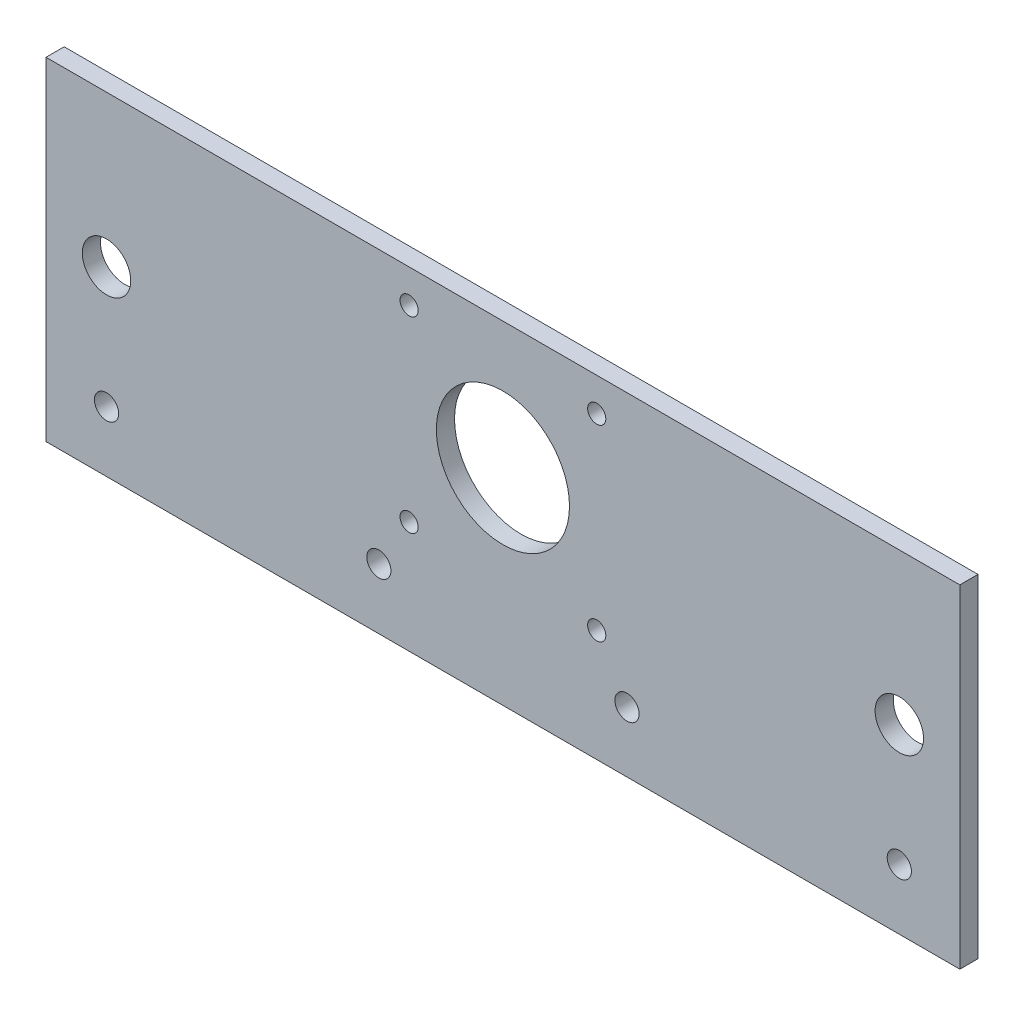
from build123d import *

# Parameters (mm, degrees)
SKIZZE1_W                       = 151
SKIZZE1_H                       = 55
AUFSATZ_LINEAR_AUSTRAGEN1_DEPTH = 3
SKIZZE2_R                       = 11
SCHNITT_LINEAR_AUSTRAGEN1_DEPTH = 17
SKIZZE3_R                       = 1.5
SCHNITT_LINEAR_AUSTRAGEN2_DEPTH = 10
SKIZZE4_R                       = 4
SCHNITT_LINEAR_AUSTRAGEN3_DEPTH = 10
SKIZZE5_R                       = 2
SCHNITT_LINEAR_AUSTRAGEN4_DEPTH = 10


with BuildPart() as part:
    # Skizze1 → Aufsatz-Linear austragen1 (new body)
    with BuildSketch(Plane.XY):
        with Locations((75.5, 27.5)):
            Rectangle(SKIZZE1_W, SKIZZE1_H)
    extrude(amount=AUFSATZ_LINEAR_AUSTRAGEN1_DEPTH)

    # Skizze2 → Schnitt-Linear austragen1 (cut)
    with BuildSketch(Plane.XY.offset(3)):
        with Locations((75.5, 34)):
            Circle(SKIZZE2_R)
    extrude(amount=-SCHNITT_LINEAR_AUSTRAGEN1_DEPTH, mode=Mode.SUBTRACT)

    # Skizze3 → Schnitt-Linear austragen2 (cut)
    with BuildSketch(Plane.XY.offset(3)):
        with Locations((91, 49.5)):
            Circle(SKIZZE3_R)
        with Locations((91, 18.5)):
            Circle(SKIZZE3_R)
        with Locations((60, 18.5)):
            Circle(SKIZZE3_R)
        with Locations((60, 49.5)):
            Circle(SKIZZE3_R)
    extrude(amount=-SCHNITT_LINEAR_AUSTRAGEN2_DEPTH, mode=Mode.SUBTRACT)

    # Skizze4 → Schnitt-Linear austragen3 (cut)
    with BuildSketch(Plane.XY.offset(3)):
        with Locations((141, 30)):
            Circle(SKIZZE4_R)
        with Locations((10, 30)):
            Circle(SKIZZE4_R)
    extrude(amount=-SCHNITT_LINEAR_AUSTRAGEN3_DEPTH, mode=Mode.SUBTRACT)

    # Skizze5 → Schnitt-Linear austragen4 (cut)
    with BuildSketch(Plane.XY.offset(3)):
        with Locations((10, 10)):
            Circle(SKIZZE5_R)
        with Locations((55, 10)):
            Circle(SKIZZE5_R)
        with Locations((96, 10)):
            Circle(SKIZZE5_R)
        with Locations((141, 10)):
            Circle(SKIZZE5_R)
    extrude(amount=-SCHNITT_LINEAR_AUSTRAGEN4_DEPTH, mode=Mode.SUBTRACT)


solid = part.part
